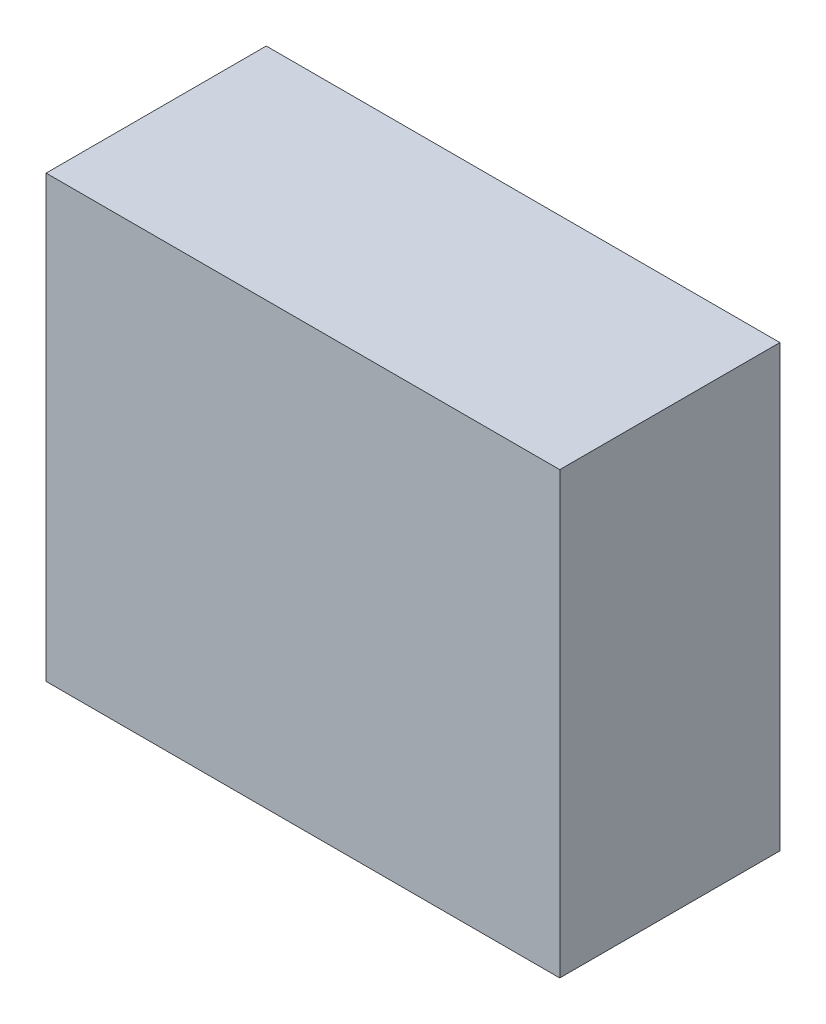
from build123d import *

# Parameters (mm, degrees)
SKETCH1_W           = 177.8
SKETCH1_H           = 76.2
BOSS_EXTRUDE1_DEPTH = 152.4


with BuildPart() as part:
    # Sketch1 → Boss-Extrude1 (new body)
    with BuildSketch(Plane(origin=(0, 0, 0), x_dir=(1, 0, 0), z_dir=(0, 1, 0))):
        Rectangle(SKETCH1_W, SKETCH1_H)
    extrude(amount=BOSS_EXTRUDE1_DEPTH)


solid = part.part
